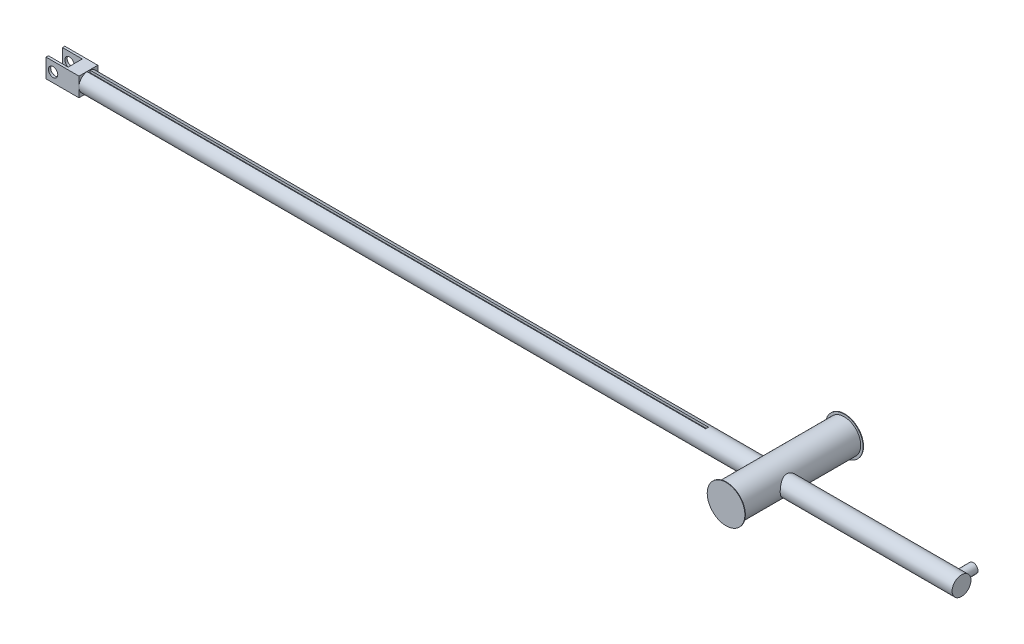
from build123d import *

# Parameters (mm, degrees)
SKETCH_1_R           = 2
EXTRUDE_1_DEPTH      = 192.4
SKETCH_2_R           = 1
EXTRUDE_2_DEPTH      = 4.5
SKETCH_3_R           = 3.5
EXTRUDE_3_DEPTH      = 10
EXTRUDE_3_DEPTH_BACK = 15.1
SKETCH_4_R           = 4
EXTRUDE_4_DEPTH      = 0.1
SKETCH_5_R           = 4
EXTRUDE_5_DEPTH      = 0.1
SKETCH_6_W           = 7
SKETCH_6_H           = 4
EXTRUDE_6_DEPTH      = 2
SKETCH_7_W           = 4.2
SKETCH_7_H           = 3
CUT_EXTRUDE_1_DEPTH  = 2
SKETCH_8_R           = 1
CUT_EXTRUDE_2_DEPTH  = 2
SKETCH_9_W           = 131.4
SKETCH_9_H           = 0.6
CUT_EXTRUDE_3_DEPTH  = 0.5


with BuildPart() as part:
    # 草图1 → 凸台-拉伸1 (new body)
    with BuildSketch(Plane(origin=(0, 0, 0), x_dir=(0, 0, -1), z_dir=(1, 0, 0))):
        Circle(SKETCH_1_R)
    extrude(amount=EXTRUDE_1_DEPTH)

    # 草图2 → 凸台-拉伸2 (add)
    with BuildSketch(Plane.XY):
        with Locations((2, 0)):
            Circle(SKETCH_2_R)
    extrude(amount=-EXTRUDE_2_DEPTH)

    # 草图3 → 凸台-拉伸3 (add, two sides)
    with BuildSketch(Plane.XY) as extrude_3_sk:
        with Locations((40, 0)):
            Circle(SKETCH_3_R)
    extrude(amount=EXTRUDE_3_DEPTH)
    extrude(extrude_3_sk.sketch, amount=-EXTRUDE_3_DEPTH_BACK)

    # 草图4 → 凸台-拉伸4 (add)
    with BuildSketch(Plane.XY.offset(10)):
        with Locations((40, 0)):
            Circle(SKETCH_4_R)
    extrude(amount=-EXTRUDE_4_DEPTH)

    # 草图5 → 凸台-拉伸5 (add)
    with BuildSketch(Plane(origin=(0, 0, -15.1), x_dir=(-1, 0, 0), z_dir=(0, 0, -1))):
        with Locations((-40, 0)):
            Circle(SKETCH_5_R)
    extrude(amount=EXTRUDE_5_DEPTH)

    # 草图6 → 凸台-拉伸6 (add, symmetric)
    with BuildSketch(Plane(origin=(0, 0, 0), x_dir=(1, 0, 0), z_dir=(0, 1, 0))):
        with Locations((188.9, 0)):
            Rectangle(SKETCH_6_W, SKETCH_6_H)
    extrude(amount=EXTRUDE_6_DEPTH, both=True)

    # 草图7 → 切除-拉伸1 (cut, symmetric)
    with BuildSketch(Plane(origin=(0, 0, 0), x_dir=(1, 0, 0), z_dir=(0, 1, 0))):
        with Locations((190.3, 0)):
            Rectangle(SKETCH_7_W, SKETCH_7_H)
    extrude(amount=CUT_EXTRUDE_1_DEPTH, both=True, mode=Mode.SUBTRACT)

    # 草图8 → 切除-拉伸2 (cut, symmetric)
    with BuildSketch(Plane.XY):
        with Locations((190.9, 0)):
            Circle(SKETCH_8_R)
    extrude(amount=CUT_EXTRUDE_2_DEPTH, both=True, mode=Mode.SUBTRACT)

    # 草图9 → 切除-拉伸3 (cut)
    with BuildSketch(Plane(origin=(0, 2, 0), x_dir=(1, 0, 0), z_dir=(0, 1, 0))):
        with Locations((119.7, 0)):
            Rectangle(SKETCH_9_W, SKETCH_9_H)
    extrude(amount=-CUT_EXTRUDE_3_DEPTH, mode=Mode.SUBTRACT)


with BuildPart() as body_2:
    # 镜向1: mirrored copy
    add(part.part.mirror(Plane(origin=(0, 0, 0), x_dir=(0, 0, 1), z_dir=(1, 0, 0))))


solid = body_2.part
